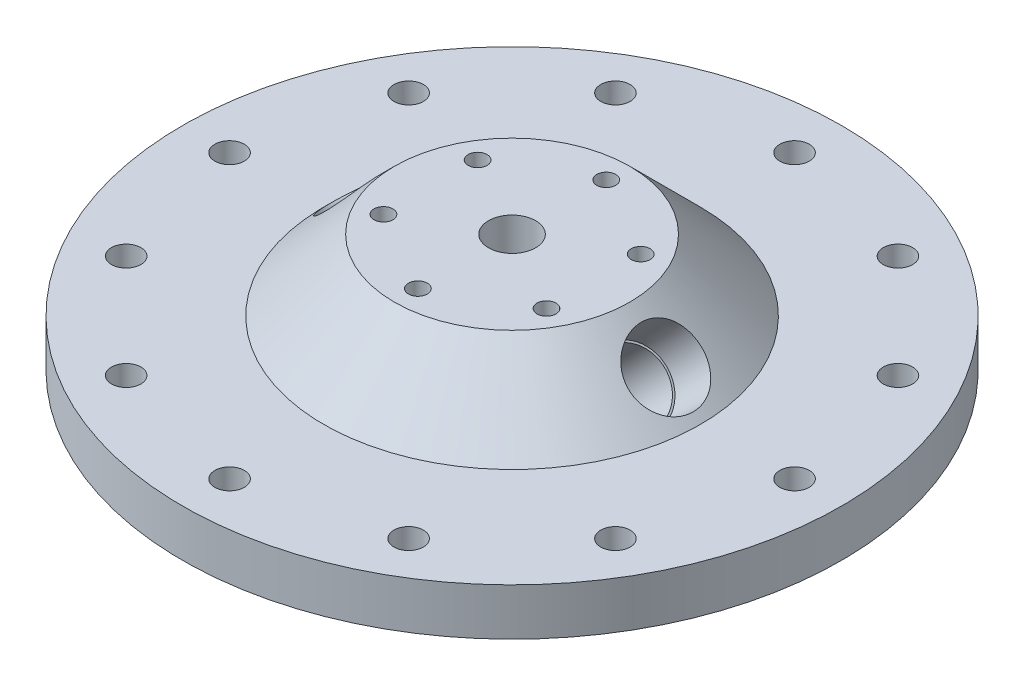
from build123d import *

# Parameters (mm, degrees)
CIRPATTERN1_COUNT                = 12
CIRPATTERN2_COUNT                = 6
F_1_8_0_125_DIAMETER_HOLE1_D     = 3.175
F_1_8_0_125_DIAMETER_HOLE1_DEPTH = 3.175
F_1_8_0_125_DIAMETER_HOLE1_TIP   = 0.953866233


with BuildPart() as part:
    # Sketch1 → Revolve1 (revolve)
    with BuildSketch(Plane.XY):
        Polygon((-6.35, 0), (-88.9, 0), (-88.9, 12.7), (-50.8, 12.7), (-31.75, 31.75), (-6.35, 31.75), align=None)
    revolve(axis=Axis((0, 0, 0), (0, 1, 0)))

    # Sketch3 → 5/16 (0.3125) Diameter Hole1 (revolve, cut)
    with BuildSketch(Plane(origin=(76.2, 12.7, 0), x_dir=(0, 0, 1), z_dir=(1, 0, 0))):
        Polygon((0, 0), (0, 31.086665582), (3.96875, 28.702), (3.96875, 0), align=None)
    f_5_16_0_3125_diameter_hole1 = revolve(axis=Axis((76.2, 19.05, 0), (0, -1, 0)), mode=Mode.SUBTRACT)

    # CirPattern1: 5/16 (0.3125) Diameter Hole1 ×12 about axis
    cirpattern1_axis = Axis((0, 0, 0), (0, 1, 0))
    for i in range(1, CIRPATTERN1_COUNT):
        add(f_5_16_0_3125_diameter_hole1.rotate(cirpattern1_axis, i * 360 / CIRPATTERN1_COUNT), mode=Mode.SUBTRACT)

    # Sketch5 → 1/2 NPT Tapped Hole1 (revolve, cut)
    with BuildSketch(Plane(origin=(41.852788136, 21.647211864, 0), x_dir=(-0.707106781, 0.707106781, 0), z_dir=(0, 0, 1))):
        Polygon((0, 0), (0, 33.939543693), (8.9281, 28.575), (8.9281, 13.462), (9.479726792, 13.462), (9.8827971, 0), align=None)
    revolve(axis=Axis((46.342916197, 26.137339924, 0), (-0.707106781, -0.707106781, 0)), mode=Mode.SUBTRACT)

    # Sketch7 → 1/2 NPT Tapped Hole2 (revolve, cut)
    with BuildSketch(Plane(origin=(-41.852788136, 21.647211864, 0), x_dir=(-0.707106781, -0.707106781, 0), z_dir=(0, 0, 1))):
        Polygon((0, 0), (0, 34.066543693), (8.9281, 28.702), (8.9281, 13.462), (9.479726792, 13.462), (9.8827971, 0), align=None)
    revolve(axis=Axis((-46.342916197, 26.137339924, 0), (0.707106781, -0.707106781, 0)), mode=Mode.SUBTRACT)

    # Sketch9 → 1/4-20 Tapped Hole1 (revolve, cut)
    with BuildSketch(Plane(origin=(21.997045256, 31.75, -12.7), x_dir=(0, 0, 1), z_dir=(1, 0, 0))):
        Polygon((0, 0), (0, 18.043816902), (2.5527, 16.51), (2.5527, 0), align=None)
    f_1_4_20_tapped_hole1 = revolve(axis=Axis((21.997045256, 38.1, -12.7), (0, -1, 0)), mode=Mode.SUBTRACT)

    # CirPattern2: 1/4-20 Tapped Hole1 ×6 about axis
    cirpattern2_axis = Axis((0, 0, 0), (0, 1, 0))
    for i in range(1, CIRPATTERN2_COUNT):
        add(f_1_4_20_tapped_hole1.rotate(cirpattern2_axis, i * 360 / CIRPATTERN2_COUNT), mode=Mode.SUBTRACT)

    # 1/8 (0.125) Diameter Hole1
    with Locations(Plane(origin=(0, 0, 0), x_dir=(-1, 0, 0), z_dir=(0, -1, 0))):
        with Locations((35.745198541, -20.6375)):
            Hole(F_1_8_0_125_DIAMETER_HOLE1_D / 2, depth=F_1_8_0_125_DIAMETER_HOLE1_DEPTH)
            with Locations((0, 0, -(F_1_8_0_125_DIAMETER_HOLE1_DEPTH + F_1_8_0_125_DIAMETER_HOLE1_TIP / 2))):  # 118° drill point
                Cone(0, F_1_8_0_125_DIAMETER_HOLE1_D / 2, F_1_8_0_125_DIAMETER_HOLE1_TIP, mode=Mode.SUBTRACT)


solid = part.part
